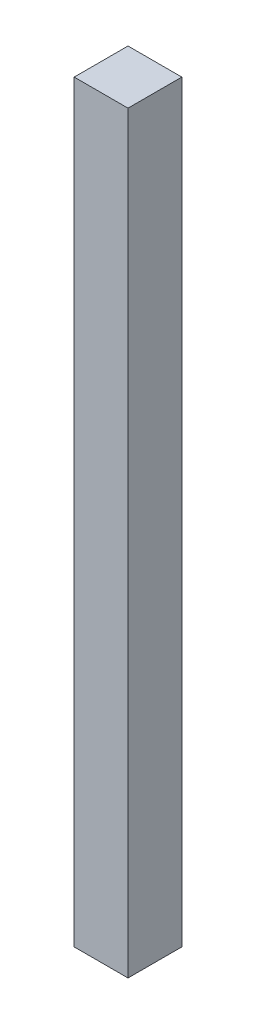
from build123d import *

# Parameters (mm, degrees)
SKETCH1_W           = 5
SKETCH1_H           = 5
BOSS_EXTRUDE1_DEPTH = 70


with BuildPart() as part:
    # Sketch1 → Boss-Extrude1 (new body)
    with BuildSketch(Plane(origin=(0, 0, 0), x_dir=(1, 0, 0), z_dir=(0, 1, 0))):
        with Locations((2.5, -2.5)):
            Rectangle(SKETCH1_W, SKETCH1_H)
    extrude(amount=BOSS_EXTRUDE1_DEPTH)


solid = part.part
